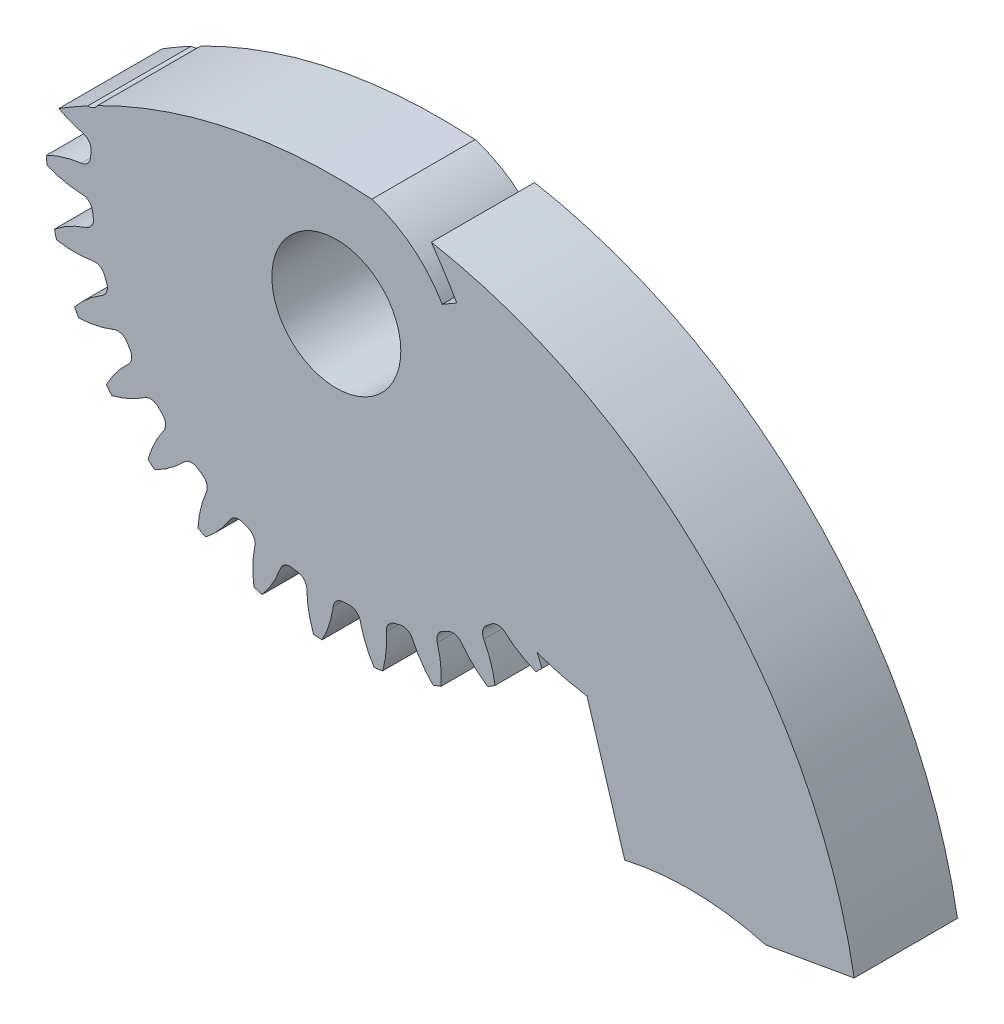
from build123d import *

# Parameters (mm, degrees)
SKETCH3_R               = 40.64
GEARBODY_DEPTH          = 9.652
TOOTHCUT_DEPTH          = 59.278472046
CIRPATTERN1_COUNT       = 30
SCALE1_SCALE_X          = 0.666666667
SCALE1_SCALE_Y          = 0.666666667
SCALE1_SCALE_Z          = 1
BOREDIA_R               = 6.025500014
BORE_DEPTH              = 12700
CUT_EXTRUDE1_DEPTH      = 40.484183443
BOSS_EXTRUDE1_DEPTH     = 9.652
BODY_TUBE_CUT_OUT_DEPTH = 59.606597768
CUT_EXTRUDE2_DEPTH      = 59.606597867


with BuildPart() as part:
    # Sketch3 → gearBody (new body)
    with BuildSketch(Plane.XY):
        Circle(SKETCH3_R)
    extrude(amount=GEARBODY_DEPTH)

    # Sketch2 → toothCut (cut, through all)
    with BuildSketch(Plane.XY):
        with BuildLine():
            ThreePointArc((34.394913865, -2.602065804), (34.422837838, -2.202062993), (34.446110053, -1.801762604))
            ThreePointArc((34.446110053, -1.801762604), (34.848551077, -0.857723348), (35.765177549, -0.396242249))
            ThreePointArc((35.765177549, -0.396242249), (42.229269138, 1.990999361), (46.880145703, 7.075559297))
            ThreePointArc((46.880145703, 7.075559297), (47.314378359, -3.026747594), (45.596443857, -12.991378223))
            ThreePointArc((45.596443857, -12.991378223), (41.631354958, -7.355646452), (35.524137196, -4.164205745))
            ThreePointArc((35.524137196, -4.164205745), (34.673784516, -3.589689241), (34.394913865, -2.602065804))
        make_face()
        with BuildLine():
            ThreePointArc((45.4750933, -11.485464069), (41.410501506, -6.509663078), (35.646600115, -3.671187658))
            ThreePointArc((35.646600115, -3.671187658), (35.08548304, -3.292084932), (34.901466352, -2.640387833))
            ThreePointArc((34.901466352, -2.640387833), (34.929801576, -2.234493965), (34.953416534, -1.828298136))
            ThreePointArc((34.953416534, -1.828298136), (35.218972856, -1.205360668), (35.823821616, -0.900845929))
            ThreePointArc((35.823821616, -0.900845929), (41.902420255, 1.180053047), (46.567899911, 5.597382731))
            ThreePointArc((46.567899911, 5.597382731), (46.807414621, -2.994316622), (45.4750933, -11.485464069))
        make_face(mode=Mode.SUBTRACT)
        with BuildLine():
            ThreePointArc((35.646600115, -3.671187658), (35.08548304, -3.292084932), (34.901466352, -2.640387833))
            ThreePointArc((34.901466352, -2.640387833), (34.929801576, -2.234493965), (34.953416534, -1.828298136))
            ThreePointArc((34.953416534, -1.828298136), (35.218972856, -1.205360668), (35.823821616, -0.900845929))
            ThreePointArc((35.823821616, -0.900845929), (41.902420255, 1.180053047), (46.567899911, 5.597382731))
            ThreePointArc((46.567899911, 5.597382731), (46.807414621, -2.994316622), (45.4750933, -11.485464069))
            ThreePointArc((45.4750933, -11.485464069), (41.410501506, -6.509663078), (35.646600115, -3.671187658))
        make_face()
    toothcut = extrude(amount=TOOTHCUT_DEPTH, mode=Mode.SUBTRACT)

    # CirPattern1: toothCut ×30 about axis
    cirpattern1_axis = Axis((0, 0, 0), (0, 0, 1))
    for i in range(1, CIRPATTERN1_COUNT):
        add(toothcut.rotate(cirpattern1_axis, i * 360 / CIRPATTERN1_COUNT), mode=Mode.SUBTRACT)


with BuildPart() as part_1:
    # Scale1: scaled about (0, 0, 4.826)
    add(part.part.scale((SCALE1_SCALE_X, SCALE1_SCALE_Y, SCALE1_SCALE_Z), about=(0, 0, 4.826)))

    # boreDia → bore (cut, symmetric)
    with BuildSketch(Plane.XY):
        Circle(BOREDIA_R)
    extrude(amount=BORE_DEPTH, both=True, mode=Mode.SUBTRACT)

    # Sketch4 → Cut-Extrude1 (cut, through all)
    with BuildSketch(Plane.XY.offset(9.652)):
        with BuildLine():
            ThreePointArc((-17.943729776, -83.856384939), (0, 11.049), (17.943729776, -83.856384939))
            ThreePointArc((17.943729776, -83.856384939), (0, 85.754712602), (-17.943729776, -83.856384939))
        make_face()
    extrude(amount=-CUT_EXTRUDE1_DEPTH, mode=Mode.SUBTRACT)

    # Sketch5 → Boss-Extrude1 (add)
    with BuildSketch(Plane.XY.offset(9.652)):
        with BuildLine():
            Line((23.424769806, -19.215611802), (26.959165805, -30.742024145))
            ThreePointArc((26.959165805, -30.742024145), (33.569316663, -30.066976699), (40.144948283, -31.021362479))
            Line((40.144948283, -31.021362479), (48.777528007, -29.49920576))
            ThreePointArc((48.777528007, -29.49920576), (34.808245264, -2.863556342), (8.00379846, 10.779035488))
            add(Edge.make_bspline(
                [(8.00379846, 10.779035488), (4.700723166, -16.48766374), (23.424769806, -19.215611802)],
                knots=[0, 0, 0, 1, 1, 1], degree=2))
        make_face()
    extrude(amount=-BOSS_EXTRUDE1_DEPTH)

    # Sketch6 → Body Tube Cut Out (cut, through all)
    with BuildSketch(Plane.XY.offset(9.652)):
        with BuildLine():
            Line((11.262487171, 6.5024), (9.898670365, 5.715))
            ThreePointArc((9.898670365, 5.715), (5.715, 9.898670365), (0, 11.43))
            ThreePointArc((0, 11.43), (4.300943022, 11.242910221), (8.569394121, 10.683054275))
            ThreePointArc((8.569394121, 10.683054275), (9.966823016, 8.625504533), (11.262487171, 6.5024))
        make_face()
    extrude(amount=-BODY_TUBE_CUT_OUT_DEPTH, mode=Mode.SUBTRACT)

    # Sketch4_7 → Cut-Extrude2 (cut, through all)
    with BuildSketch(Plane.XY.offset(9.652)):
        with BuildLine():
            ThreePointArc((17.943729776, -83.856384939), (0, 11.049), (-17.943729776, -83.856384939))
            ThreePointArc((-17.943729776, -83.856384939), (0, 85.754712602), (17.943729776, -83.856384939))
        make_face()
    extrude(amount=-CUT_EXTRUDE2_DEPTH, mode=Mode.SUBTRACT)


solid = part_1.part
